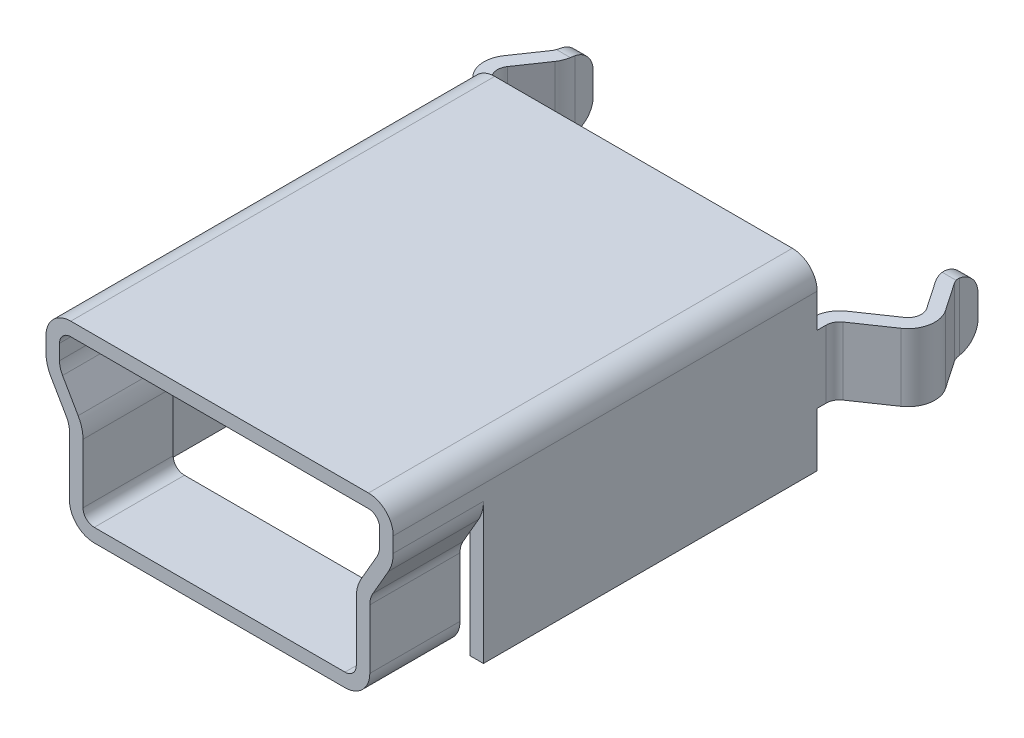
from build123d import *

# Parameters (mm, degrees)
BOSS_EXTRUDE1_DEPTH = 2
BOSS_EXTRUDE2_DEPTH = 7.4
BOSS_EXTRUDE3_DEPTH = 1.5
FILLET1_R           = 0.5


with BuildPart() as part:
    # Sketch2 → Boss-Extrude1 (new body)
    with BuildSketch(Plane.XY):
        with BuildLine():
            Line((0, 0), (2.78, 0))
            ThreePointArc((2.78, 0), (3.16890873, 0.16109127), (3.33, 0.55))
            Line((3.33, 0.55), (3.33, 1.866025404))
            ThreePointArc((3.33, 1.866025404), (3.347037087, 1.995434926), (3.396987298, 2.116025404))
            Line((3.396987298, 2.116025404), (3.742820323, 2.715025774))
            ThreePointArc((3.742820323, 2.715025774), (3.822740661, 2.907970538), (3.85, 3.115025774))
            Line((3.85, 3.115025774), (3.85, 3.45))
            ThreePointArc((3.85, 3.45), (3.68890873, 3.83890873), (3.3, 4))
            Line((3.3, 4), (0, 4))
            Line((0, 4), (0, 3.7))
            Line((0, 3.7), (3.3, 3.7))
            ThreePointArc((3.3, 3.7), (3.476776695, 3.626776695), (3.55, 3.45))
            Line((3.55, 3.45), (3.55, 3.115025774))
            ThreePointArc((3.55, 3.115025774), (3.532962913, 2.985616251), (3.483012702, 2.865025774))
            Line((3.483012702, 2.865025774), (3.137179677, 2.266025404))
            ThreePointArc((3.137179677, 2.266025404), (3.057259339, 2.07308064), (3.03, 1.866025404))
            Line((3.03, 1.866025404), (3.03, 0.55))
            ThreePointArc((3.03, 0.55), (2.956776695, 0.373223305), (2.78, 0.3))
            Line((2.78, 0.3), (0, 0.3))
            Line((0, 0.3), (0, 0))
        make_face()
    extrude(amount=-BOSS_EXTRUDE1_DEPTH)

    # Sketch4 → Boss-Extrude2 (add)
    with BuildSketch(Plane(origin=(0, 0, -2), x_dir=(-1, 0, 0), z_dir=(0, 0, -1))):
        with BuildLine():
            Line((-3.55, 0), (-3.85, 0))
            Line((-3.85, 0), (-3.85, 3.45))
            ThreePointArc((-3.85, 3.45), (-3.68890873, 3.83890873), (-3.3, 4))
            Line((-3.3, 4), (0, 4))
            Line((0, 4), (0, 3.7))
            Line((0, 3.7), (-3.3, 3.7))
            ThreePointArc((-3.3, 3.7), (-3.476776695, 3.626776695), (-3.55, 3.45))
            Line((-3.55, 3.45), (-3.55, 0))
        make_face()
    extrude(amount=BOSS_EXTRUDE2_DEPTH)

    # Sketch5 → Boss-Extrude3 (add)
    with BuildSketch(Plane(origin=(0, 1.2, 0), x_dir=(1, 0, 0), z_dir=(0, 1, 0))):
        with BuildLine():
            Line((3.85, 9.4), (3.55, 9.4))
            Line((3.55, 9.4), (3.55, 9.6))
            ThreePointArc((3.55, 9.6), (3.619329194, 9.879979456), (3.811294986, 10.095256412))
            Line((3.811294986, 10.095256412), (4.569352507, 10.613690656))
            ThreePointArc((4.569352507, 10.613690656), (4.69484989, 10.805969585), (4.647628206, 11.030671369))
            Line((4.647628206, 11.030671369), (4.221287524, 11.654069155))
            ThreePointArc((4.221287524, 11.654069155), (4.143327639, 11.815508616), (4.116543936, 11.99277417))
            Line((4.116543936, 11.99277417), (4.116543936, 12.4))
            Line((4.116543936, 12.4), (4.416543936, 12.4))
            Line((4.416543936, 12.4), (4.416543936, 11.99277417))
            ThreePointArc((4.416543936, 11.99277417), (4.429935787, 11.904141393), (4.46891573, 11.823421663))
            Line((4.46891573, 11.823421663), (4.895256412, 11.200023877))
            ThreePointArc((4.895256412, 11.200023877), (4.98969978, 10.750620308), (4.738705014, 10.366062451))
            Line((4.738705014, 10.366062451), (3.980647493, 9.847628206))
            ThreePointArc((3.980647493, 9.847628206), (3.884664597, 9.739989728), (3.85, 9.6))
            Line((3.85, 9.6), (3.85, 9.4))
        make_face()
    extrude(amount=BOSS_EXTRUDE3_DEPTH)

    # Fillet1
    fillet1_edges = [part.edges().sort_by_distance(p)[0] for p in [
        (4.266543936, 1.2, -12.4),
        (4.266543936, 2.7, -12.4),
    ]]
    fillet(fillet1_edges, radius=FILLET1_R)

    # Mirror1: part across plane


with BuildPart() as part_1:
    add(part.part)
    add(part.part.mirror(Plane(origin=(0, 4, -2), x_dir=(0, 0, 1), z_dir=(-1, 0, 0))))


solid = part_1.part
